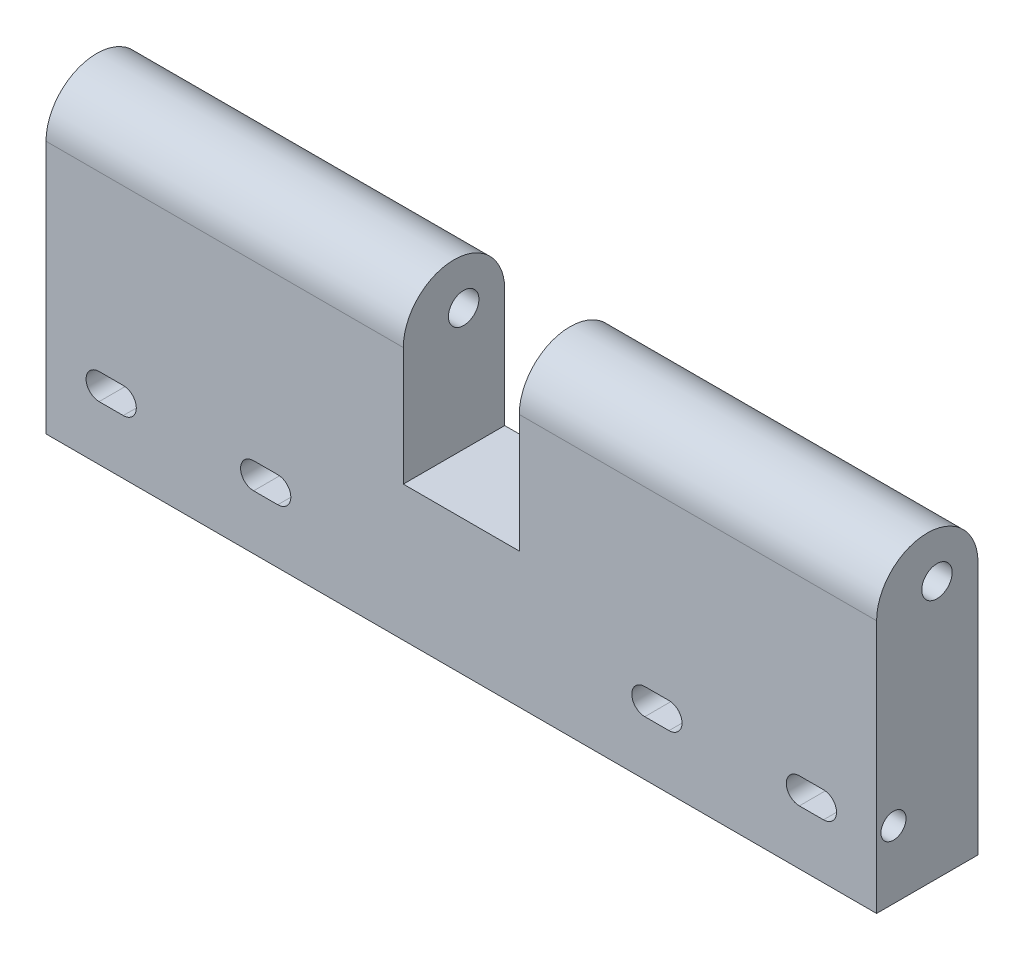
from build123d import *

# Parameters (mm, degrees)
SKETCH_1_W          = 172.02
SKETCH_1_H          = 28
EXTRUDE_1_DEPTH     = 21
SKETCH_2_W          = 74
SKETCH_2_H          = 21
EXTRUDE_2_DEPTH     = 35
CUT_EXTRUDE_1_DEPTH = 173.02
SKETCH_4_R          = 3.15
CUT_EXTRUDE_2_DEPTH = 173.02
SKETCH_6_R          = 2.6
CUT_EXTRUDE_3_DEPTH = 8
SKETCH_7_R          = 2.6
CUT_EXTRUDE_4_DEPTH = 8


with BuildPart() as part:
    # 草图1 → 凸台-拉伸1 (new body)
    with BuildSketch(Plane.XY):
        Rectangle(SKETCH_1_W, SKETCH_1_H)
        with BuildLine():
            Line((75.01, -2.7), (70.01, -2.7))
            ThreePointArc((70.01, -2.7), (67.31, 0), (70.01, 2.7))
            Line((70.01, 2.7), (75.01, 2.7))
            ThreePointArc((75.01, 2.7), (77.71, 0), (75.01, -2.7))
        make_face(mode=Mode.SUBTRACT)
        with BuildLine():
            Line((43.01, -2.7), (38.01, -2.7))
            ThreePointArc((38.01, -2.7), (35.31, 0), (38.01, 2.7))
            Line((38.01, 2.7), (43.01, 2.7))
            ThreePointArc((43.01, 2.7), (45.71, 0), (43.01, -2.7))
        make_face(mode=Mode.SUBTRACT)
        with BuildLine():
            Line((-70.01, -2.7), (-75.01, -2.7))
            ThreePointArc((-75.01, -2.7), (-77.71, 0), (-75.01, 2.7))
            Line((-75.01, 2.7), (-70.01, 2.7))
            ThreePointArc((-70.01, 2.7), (-67.31, 0), (-70.01, -2.7))
        make_face(mode=Mode.SUBTRACT)
        with BuildLine():
            Line((-43.01, 2.7), (-38.01, 2.7))
            ThreePointArc((-38.01, 2.7), (-35.31, 0), (-38.01, -2.7))
            Line((-38.01, -2.7), (-43.01, -2.7))
            ThreePointArc((-43.01, -2.7), (-45.71, 0), (-43.01, 2.7))
        make_face(mode=Mode.SUBTRACT)
    extrude(amount=EXTRUDE_1_DEPTH)

    # 草图2 → 凸台-拉伸2 (add)
    with BuildSketch(Plane(origin=(0, 14, 0), x_dir=(1, 0, 0), z_dir=(0, 1, 0))):
        with Locations((-49.01, -10.5)):
            Rectangle(SKETCH_2_W, SKETCH_2_H)
        with Locations((49.01, -10.5)):
            Rectangle(SKETCH_2_W, SKETCH_2_H)
    extrude(amount=EXTRUDE_2_DEPTH)

    # 草图3 → 切除-拉伸1 (cut, through all)
    with BuildSketch(Plane(origin=(86.01, 0, 0), x_dir=(0, 0, -1), z_dir=(1, 0, 0))):
        with BuildLine():
            Line((0, 49), (-10.5, 49))
            ThreePointArc((-10.5, 49), (-3.075378798, 45.924621202), (0, 38.5))
            Line((0, 38.5), (0, 49))
        make_face()
        with BuildLine():
            Line((-10.5, 49), (-21, 49))
            Line((-21, 49), (-21, 38.5))
            ThreePointArc((-21, 38.5), (-17.924621202, 45.924621202), (-10.5, 49))
        make_face()
    extrude(amount=-CUT_EXTRUDE_1_DEPTH, mode=Mode.SUBTRACT)

    # 草图4 → 切除-拉伸2 (cut, through all)
    with BuildSketch(Plane(origin=(86.01, 0, 0), x_dir=(0, 0, -1), z_dir=(1, 0, 0))):
        with Locations((-8.500165561, 39.35)):
            Circle(SKETCH_4_R)
    extrude(amount=-CUT_EXTRUDE_2_DEPTH, mode=Mode.SUBTRACT)

    # 草图6 → 切除-拉伸3 (cut)
    with BuildSketch(Plane(origin=(86.01, 0, 0), x_dir=(0, 0, -1), z_dir=(1, 0, 0))):
        with Locations((-17.5, 0)):
            Circle(SKETCH_6_R)
    extrude(amount=-CUT_EXTRUDE_3_DEPTH, mode=Mode.SUBTRACT)

    # 草图7 → 切除-拉伸4 (cut)
    with BuildSketch(Plane.ZY.offset(86.01)):
        with Locations((17.5, 0)):
            Circle(SKETCH_7_R)
    extrude(amount=-CUT_EXTRUDE_4_DEPTH, mode=Mode.SUBTRACT)


solid = part.part
